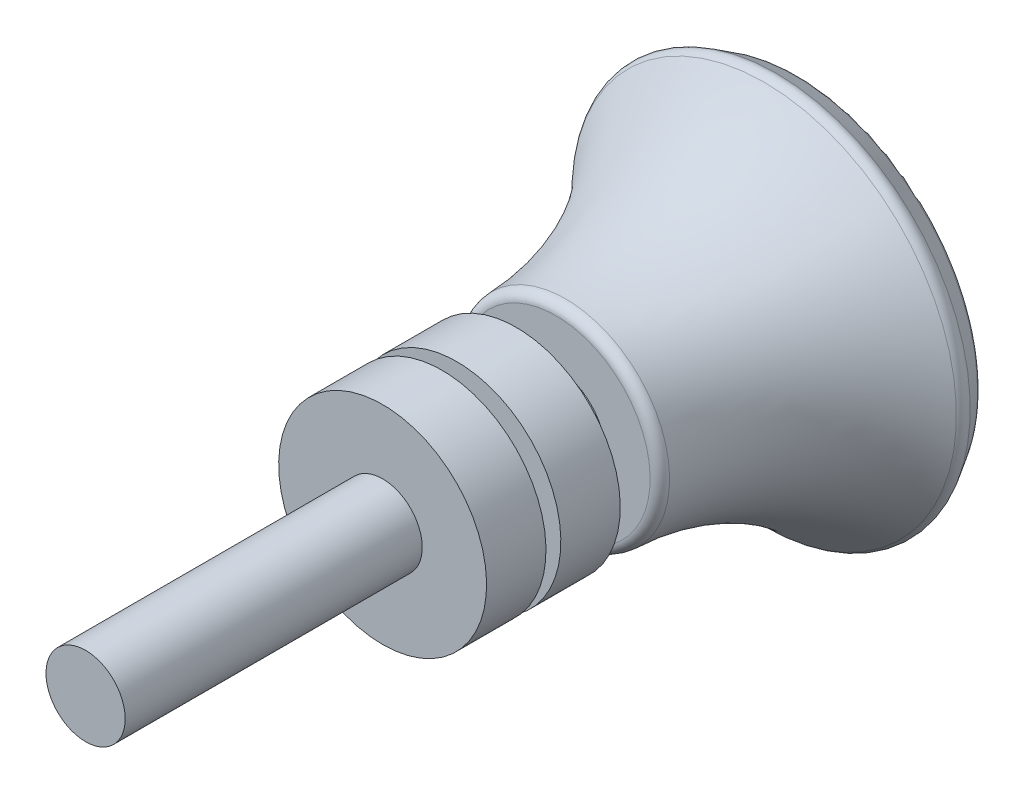
from build123d import *


with BuildPart() as part:
    # Эскиз1 → Повернуть1 (revolve)
    with BuildSketch(Plane(origin=(0, 0, 0), x_dir=(0, 0, -1), z_dir=(1, 0, 0))):
        with BuildLine():
            Line((-37.5, 0), (-37.5, 4))
            Line((-37.5, 4), (-7.5, 4))
            Line((-7.5, 4), (-7.5, 10.5))
            Line((-7.5, 10.5), (-1.5, 10.5))
            Line((-1.5, 10.5), (-1.5, 5))
            Line((-1.5, 5), (0, 5))
            Line((0, 5), (0, 10.5))
            Line((0, 10.5), (6, 10.5))
            Line((6, 10.5), (6, 5))
            Line((6, 5), (10, 5))
            Line((10, 5), (10, 9.516531243))
            ThreePointArc((10, 9.516531243), (10.281302062, 10.211853667), (10.966946547, 10.515984828))
            ThreePointArc((10.966946547, 10.515984828), (21.86672187, 13.014935813), (31.032522672, 19.421023056))
            ThreePointArc((31.032522672, 19.421023056), (31.622642119, 19.717638439), (32.268965333, 19.581668037))
            Line((32.268965333, 19.581668037), (34.156309404, 18.440297549))
            ThreePointArc((34.156309404, 18.440297549), (34.606360099, 17.837352598), (34.508702483, 17.091328984))
            ThreePointArc((34.508702483, 17.091328984), (31.146131827, 8.838013416), (30, 0))
            Line((30, 0), (-37.5, 0))
        make_face()
    revolve(axis=Axis((0, 0, 37.5), (0, 0, -1)))


solid = part.part
